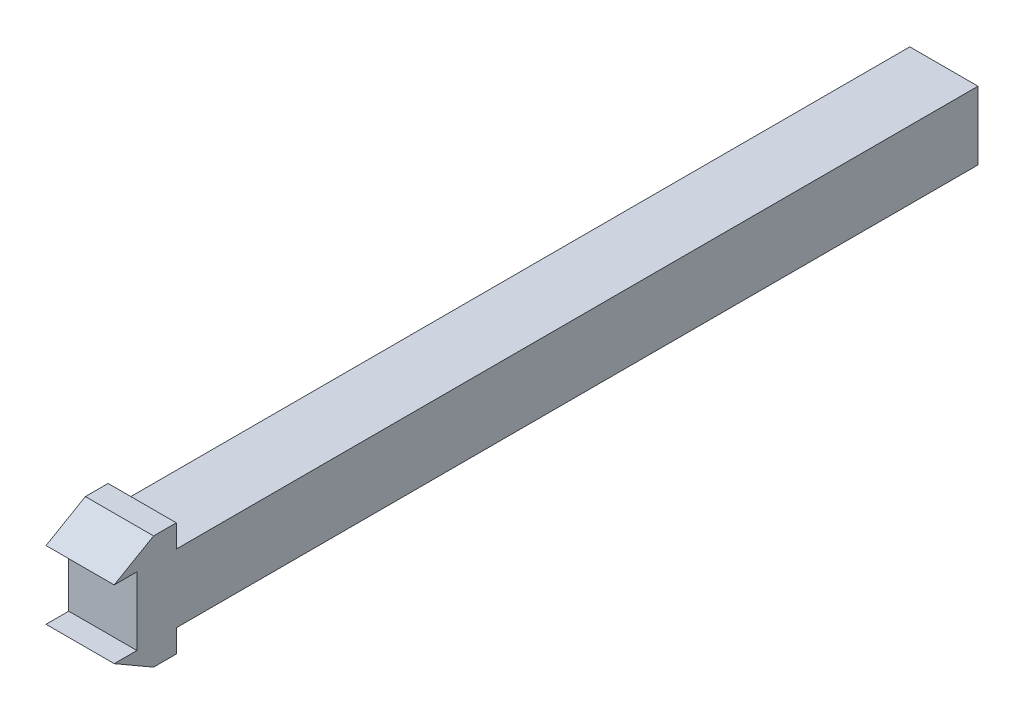
from build123d import *

# Parameters (mm, degrees)
SKETCH1_W           = 15
SKETCH1_H           = 15
BOSS_EXTRUDE1_DEPTH = 190
BOSS_EXTRUDE2_DEPTH = 15
SKETCH3_W           = 15
SKETCH3_H           = 15
CUT_EXTRUDE1_DEPTH  = 5


with BuildPart() as part:
    # Sketch1 → Boss-Extrude1 (new body)
    with BuildSketch(Plane.XY):
        Rectangle(SKETCH1_W, SKETCH1_H)
    extrude(amount=BOSS_EXTRUDE1_DEPTH)

    # Sketch2 → Boss-Extrude2 (add)
    with BuildSketch(Plane.ZY.offset(7.5)):
        Polygon((190, 7.5), (181.339745962, 12.5), (176.339745962, 12.5), (176.339745962, 7.5), align=None)
        Polygon((176.339745962, -12.5), (176.339745962, -7.5), (190, -7.5), (181.339745962, -12.5), align=None)
    extrude(amount=-BOSS_EXTRUDE2_DEPTH)

    # Sketch3 → Cut-Extrude1 (cut)
    with BuildSketch(Plane.XY.offset(190)):
        Rectangle(SKETCH3_W, SKETCH3_H)
    extrude(amount=-CUT_EXTRUDE1_DEPTH, mode=Mode.SUBTRACT)


solid = part.part
